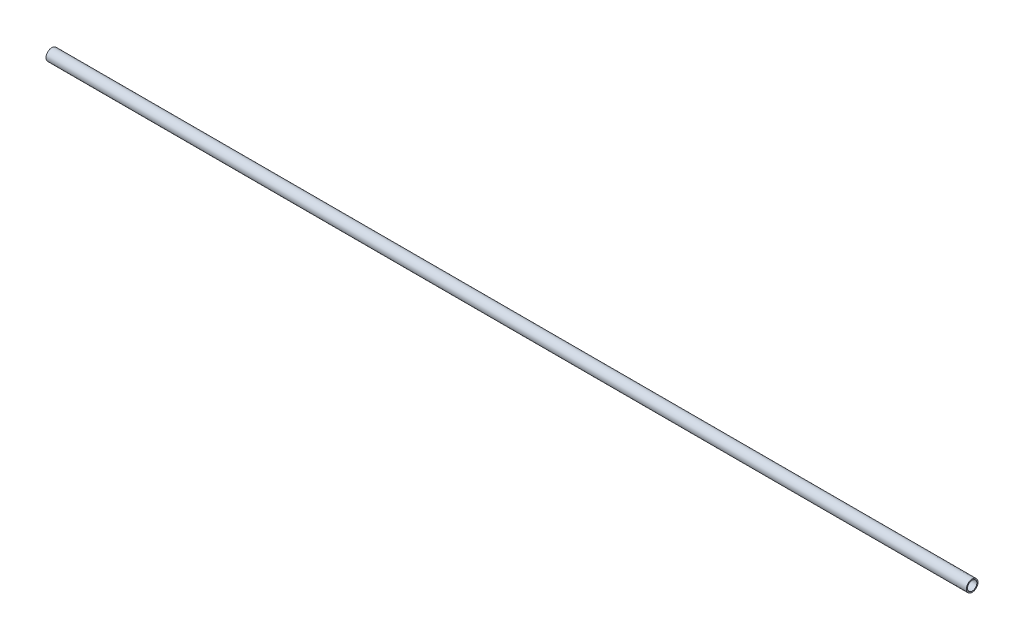
from build123d import *

# Parameters (mm, degrees)
SKETCH1_R           = 0.254
SKETCH1_R_2         = 0.2032
BOSS_EXTRUDE1_DEPTH = 40
SKETCH5_R           = 0.2
CUT_EXTRUDE1_DEPTH  = 10


with BuildPart() as part:
    # Sketch1 → Boss-Extrude1 (new body)
    with BuildSketch(Plane(origin=(0, 0, 0), x_dir=(0, 0, -1), z_dir=(1, 0, 0))):
        Circle(SKETCH1_R)
        Circle(SKETCH1_R_2, mode=Mode.SUBTRACT)
    extrude(amount=BOSS_EXTRUDE1_DEPTH)

    # Sketch5 → Cut-Extrude1 (cut)
    with BuildSketch(Plane(origin=(0, 0, 0), x_dir=(1, 0, 0), z_dir=(0, 1, 0))):
        with Locations((39.419659362, 0)):
            Circle(SKETCH5_R)
    extrude(amount=-CUT_EXTRUDE1_DEPTH, mode=Mode.SUBTRACT)


solid = part.part
